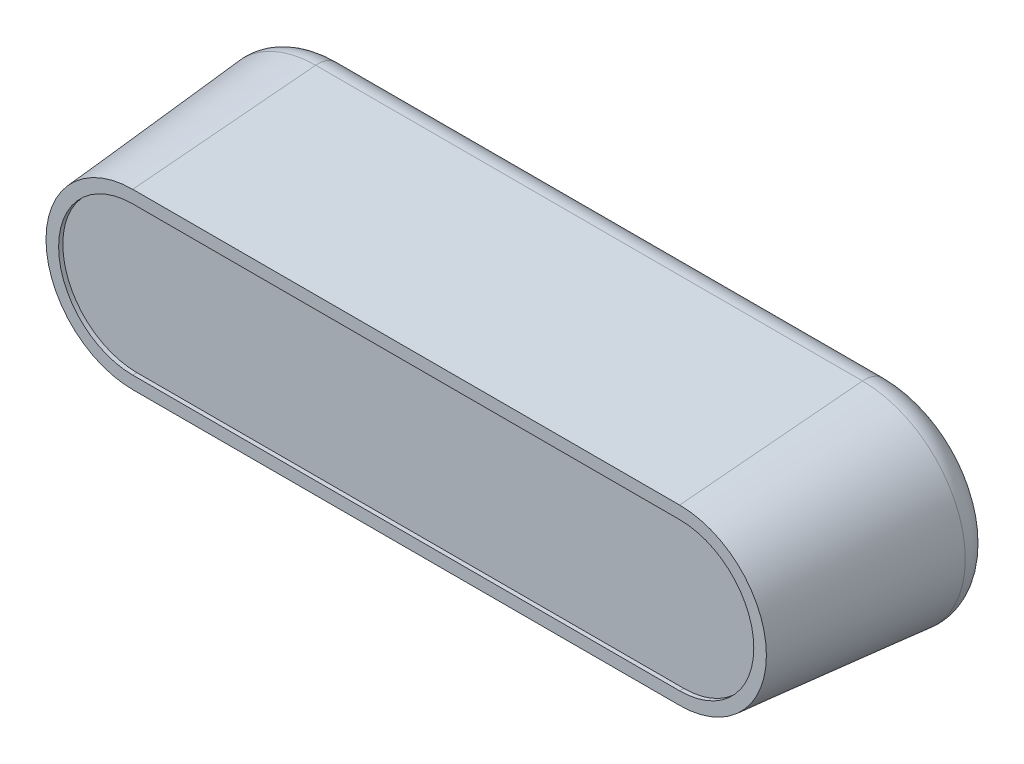
from build123d import *

# Parameters (mm, degrees)
BOSS_EXTRUDE1_DEPTH = 25
BOSS_EXTRUDE1_TAPER = 5
FILLET1_R           = 3
CUT_EXTRUDE1_DEPTH  = 0.5
BOSS_EXTRUDE2_REACH = 26.726
SKETCH5_W           = 65
SKETCH5_H           = 9
SKETCH6_R           = 2.5
CUT_EXTRUDE2_DEPTH  = 8


with BuildPart() as part:
    # Sketch1 → Boss-Extrude1 (new body)
    with BuildSketch(Plane.XY):
        with BuildLine():
            ThreePointArc((-32.5, 12.5), (-45, 0), (-32.5, -12.5))
            Line((-32.5, -12.5), (32.5, -12.5))
            ThreePointArc((32.5, -12.5), (45, 0), (32.5, 12.5))
            Line((32.5, 12.5), (-32.5, 12.5))
        make_face()
    extrude(amount=BOSS_EXTRUDE1_DEPTH, taper=BOSS_EXTRUDE1_TAPER)

    # Fillet1
    fillet1_edges = [part.edges().sort_by_distance(p)[0] for p in [
        (0, 12.5, 0),
        (45, 0, 0),
        (0, -12.5, 0),
        (-45, 0, 0),
    ]]
    fillet(fillet1_edges, radius=FILLET1_R)

    # Sketch4 → Cut-Extrude1 (cut)
    with BuildSketch(Plane.XY.offset(25)):
        with BuildLine():
            Line((-32.5, -8.812783412), (32.5, -8.812783412))
            ThreePointArc((32.5, -8.812783412), (41.312783412, 0), (32.5, 8.812783412))
            Line((32.5, 8.812783412), (-32.5, 8.812783412))
            ThreePointArc((-32.5, 8.812783412), (-41.312783412, 0), (-32.5, -8.812783412))
        make_face()
    extrude(amount=-CUT_EXTRUDE1_DEPTH, mode=Mode.SUBTRACT)

    # Sketch5 → Boss-Extrude2 (add, up to next)
    with BuildSketch(Plane(origin=(0, -12.5, 0), x_dir=(1, 0, 0), z_dir=(0, 1, 0)), mode=Mode.PRIVATE) as boss_extrude2_sk1:
        with Locations((0, -7.761467228)):
            Rectangle(SKETCH5_W, SKETCH5_H)
    boss_extrude2_tool1 = extrude(boss_extrude2_sk1.sketch, amount=BOSS_EXTRUDE2_REACH, mode=Mode.PRIVATE) - part.part
    add(boss_extrude2_tool1.solids().sort_by_distance((0, -12.5, 7.761467))[0])

    # Sketch6 → Cut-Extrude2 (cut)
    with BuildSketch(Plane.XZ.offset(12.5)):
        with Locations((0, 8)):
            Circle(SKETCH6_R)
    extrude(amount=-CUT_EXTRUDE2_DEPTH, mode=Mode.SUBTRACT)


solid = part.part
